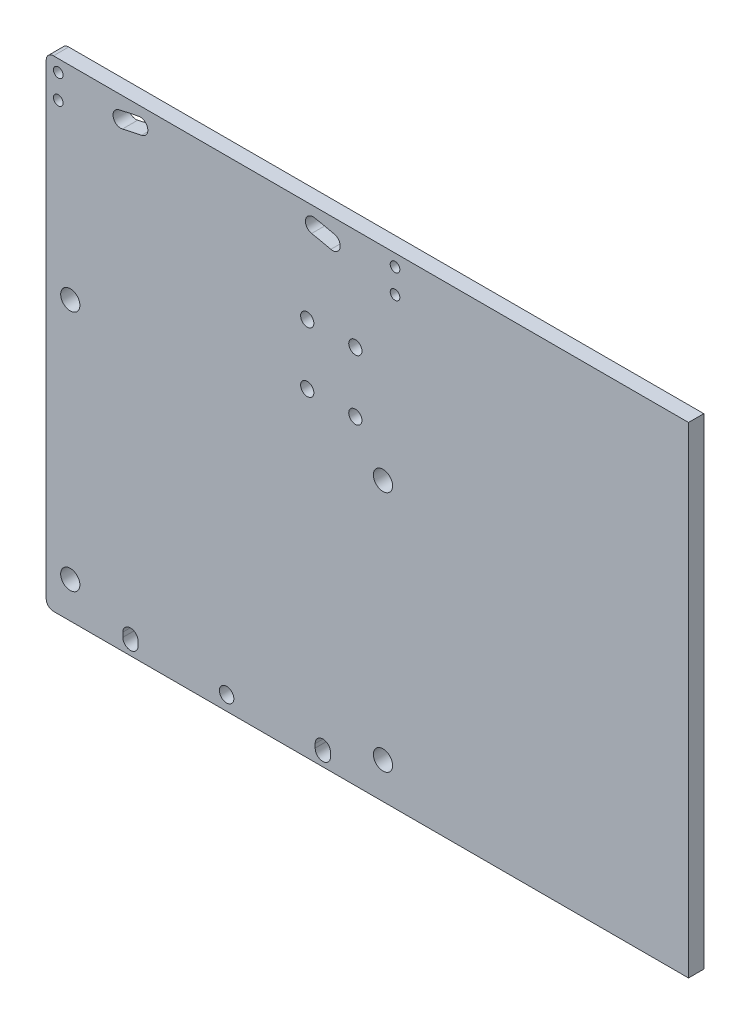
from build123d import *

# Parameters (mm, degrees)
SKETCH1_R           = 4
BOSS_EXTRUDE1_DEPTH = 6.35
SKETCH2_R           = 3
CUT_EXTRUDE1_DEPTH  = 10
SKETCH3_R           = 2
CUT_EXTRUDE2_DEPTH  = 7.35
SKETCH4_R           = 2.75
CUT_EXTRUDE3_DEPTH  = 10
BOSS_EXTRUDE2_DEPTH = 6.35


with BuildPart() as part:
    # Sketch1 → Boss-Extrude1 (new body)
    with BuildSketch(Plane.XY):
        with BuildLine():
            Line((72, 134.675), (-72, 134.675))
            ThreePointArc((-72, 134.675), (-74.121320344, 133.796320344), (-75, 131.675))
            Line((-75, 131.675), (-75, -62.325))
            ThreePointArc((-75, -62.325), (-74.121320344, -64.446320344), (-72, -65.325))
            Line((-72, -65.325), (72, -65.325))
            ThreePointArc((72, -65.325), (74.121320344, -64.446320344), (75, -62.325))
            Line((75, -62.325), (75, 131.675))
            ThreePointArc((75, 131.675), (74.121320344, 133.796320344), (72, 134.675))
        make_face()
        with Locations((-65, 50.325)):
            Circle(SKETCH1_R, mode=Mode.SUBTRACT)
        with Locations((-65, -50.325)):
            Circle(SKETCH1_R, mode=Mode.SUBTRACT)
        with Locations((65, -50.325)):
            Circle(SKETCH1_R, mode=Mode.SUBTRACT)
        with Locations((65, 50.325)):
            Circle(SKETCH1_R, mode=Mode.SUBTRACT)
    extrude(amount=BOSS_EXTRUDE1_DEPTH)

    # Sketch2 → Cut-Extrude1 (cut)
    with BuildSketch(Plane.XY.offset(6.35)):
        with Locations((0, -59.325)):
            Circle(SKETCH2_R)
        with BuildLine():
            ThreePointArc((-36.53351789, 130.62609934), (-40.668585297, 129.78392163), (-44.784296659, 128.851738315))
            ThreePointArc((-44.784296659, 128.851738315), (-47.141646379, 125.021894676), (-43.31180274, 122.664544956))
            ThreePointArc((-43.31180274, 122.664544956), (-39.331414703, 123.56607837), (-35.332307043, 124.380565536))
            ThreePointArc((-35.332307043, 124.380565536), (-32.810145565, 128.103937862), (-36.53351789, 130.62609934))
        make_face()
        with BuildLine():
            ThreePointArc((-43.164725519, -58.383142339), (-43.175, -59.325), (-43.164725519, -60.266857661))
            ThreePointArc((-43.164725519, -60.266857661), (-39.921218823, -63.371839837), (-36.816236647, -60.128333141))
            ThreePointArc((-36.816236647, -60.128333141), (-36.825, -59.325), (-36.816236647, -58.521666859))
            ThreePointArc((-36.816236647, -58.521666859), (-39.921218823, -55.278160163), (-43.164725519, -58.383142339))
        make_face()
        with BuildLine():
            ThreePointArc((36.53351789, 130.62609934), (40.668585297, 129.78392163), (44.784296659, 128.851738315))
            ThreePointArc((44.784296659, 128.851738315), (47.141646379, 125.021894676), (43.31180274, 122.664544956))
            ThreePointArc((43.31180274, 122.664544956), (39.331414703, 123.56607837), (35.332307043, 124.380565536))
            ThreePointArc((35.332307043, 124.380565536), (32.810145565, 128.103937862), (36.53351789, 130.62609934))
        make_face()
        with BuildLine():
            ThreePointArc((43.164725519, -58.383142339), (43.175, -59.325), (43.164725519, -60.266857661))
            ThreePointArc((43.164725519, -60.266857661), (39.921218823, -63.371839837), (36.816236647, -60.128333141))
            ThreePointArc((36.816236647, -60.128333141), (36.825, -59.325), (36.816236647, -58.521666859))
            ThreePointArc((36.816236647, -58.521666859), (39.921218823, -55.278160163), (43.164725519, -58.383142339))
        make_face()
    extrude(amount=-CUT_EXTRUDE1_DEPTH, mode=Mode.SUBTRACT)

    # Sketch3 → Cut-Extrude2 (cut, through all)
    with BuildSketch(Plane.XY.offset(6.35)):
        with Locations((-70, 129.675)):
            Circle(SKETCH3_R)
        with Locations((-70, 119.675)):
            Circle(SKETCH3_R)
        with Locations((70, 119.675)):
            Circle(SKETCH3_R)
        with Locations((70, 129.675)):
            Circle(SKETCH3_R)
    extrude(amount=-CUT_EXTRUDE2_DEPTH, mode=Mode.SUBTRACT)

    # Sketch4 → Cut-Extrude3 (cut)
    with BuildSketch(Plane(origin=(-33.865437688, -165.327994616, 0), x_dir=(-1, 0, 0), z_dir=(0, 0, -1))):
        with Locations((-67.365437688, 232.826497308)):
            Circle(SKETCH4_R)
        with Locations((-87.365437688, 232.826497308)):
            Circle(SKETCH4_R)
        with Locations((-87.365437688, 257.826497308)):
            Circle(SKETCH4_R)
        with Locations((-67.365437688, 257.826497308)):
            Circle(SKETCH4_R)
    extrude(amount=-CUT_EXTRUDE3_DEPTH, mode=Mode.SUBTRACT)

    # Sketch5 → Boss-Extrude2 (add)
    with BuildSketch(Plane.XY.offset(6.35)):
        with BuildLine():
            Line((72, 134.675), (192, 134.675))
            Line((192, 134.675), (192, -65.325))
            Line((192, -65.325), (72, -65.325))
            ThreePointArc((72, -65.325), (74.121320344, -64.446320344), (75, -62.325))
            Line((75, -62.325), (75, 131.675))
            ThreePointArc((75, 131.675), (74.121320344, 133.796320344), (72, 134.675))
        make_face()
    extrude(amount=-BOSS_EXTRUDE2_DEPTH)


solid = part.part
